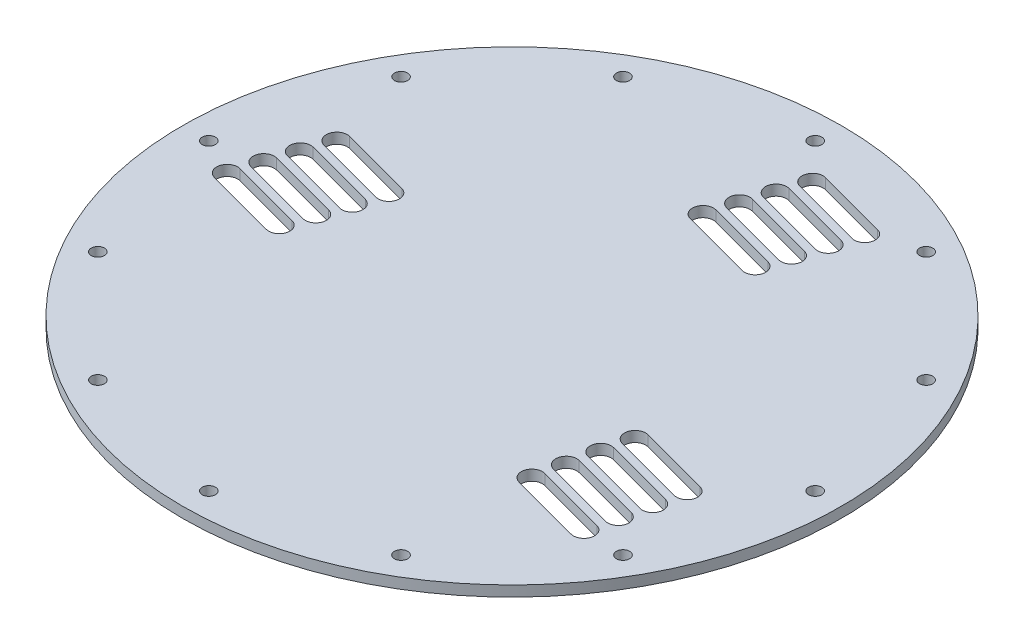
from build123d import *

# Parameters (mm, degrees)
SKETCH1_R           = 125
SKETCH1_R_2         = 2.5
BOSS_EXTRUDE1_DEPTH = 4


with BuildPart() as part:
    # Sketch1 → Boss-Extrude1 (new body)
    with BuildSketch(Plane(origin=(0, 0, 0), x_dir=(1, 0, 0), z_dir=(0, 1, 0))):
        Circle(SKETCH1_R)
        with Locations((-115, 0)):
            Circle(SKETCH1_R_2, mode=Mode.SUBTRACT)
        with Locations((-99.592921435, 57.5)):
            Circle(SKETCH1_R_2, mode=Mode.SUBTRACT)
        with Locations((-57.5, 99.592921435)):
            Circle(SKETCH1_R_2, mode=Mode.SUBTRACT)
        with Locations((0, 115)):
            Circle(SKETCH1_R_2, mode=Mode.SUBTRACT)
        with Locations((57.5, 99.592921435)):
            Circle(SKETCH1_R_2, mode=Mode.SUBTRACT)
        with Locations((99.592921435, 57.5)):
            Circle(SKETCH1_R_2, mode=Mode.SUBTRACT)
        with Locations((115, 0)):
            Circle(SKETCH1_R_2, mode=Mode.SUBTRACT)
        with Locations((99.592921435, -57.5)):
            Circle(SKETCH1_R_2, mode=Mode.SUBTRACT)
        with Locations((57.5, -99.592921435)):
            Circle(SKETCH1_R_2, mode=Mode.SUBTRACT)
        with Locations((0, -115)):
            Circle(SKETCH1_R_2, mode=Mode.SUBTRACT)
        with Locations((-57.5, -99.592921435)):
            Circle(SKETCH1_R_2, mode=Mode.SUBTRACT)
        with Locations((-99.592921435, -57.5)):
            Circle(SKETCH1_R_2, mode=Mode.SUBTRACT)
        with BuildLine():
            Line((-89.732773716, 28.184928973), (-62.744806129, 20.953524853))
            ThreePointArc((-62.744806129, 20.953524853), (-59.916379005, 16.054545368), (-64.81535849, 13.226118243))
            Line((-64.81535849, 13.226118243), (-91.803326077, 20.457522363))
            ThreePointArc((-91.803326077, 20.457522363), (-94.631753202, 25.356501849), (-89.732773716, 28.184928973))
        make_face(mode=Mode.SUBTRACT)
        with BuildLine():
            Line((-93.131960654, 17.723307294), (-66.143993068, 10.491903174))
            ThreePointArc((-66.143993068, 10.491903174), (-63.315565943, 5.592923688), (-68.214545428, 2.764496564))
            Line((-68.214545428, 2.764496564), (-95.202513015, 9.995900684))
            ThreePointArc((-95.202513015, 9.995900684), (-98.03094014, 14.894880169), (-93.131960654, 17.723307294))
        make_face(mode=Mode.SUBTRACT)
        with BuildLine():
            Line((-96.531147592, 7.261685615), (-69.543180006, 0.030281495))
            ThreePointArc((-69.543180006, 0.030281495), (-66.714752881, -4.868697991), (-71.613732367, -7.697125116))
            Line((-71.613732367, -7.697125116), (-98.601699953, -0.465720995))
            ThreePointArc((-98.601699953, -0.465720995), (-101.430127078, 4.43325849), (-96.531147592, 7.261685615))
        make_face(mode=Mode.SUBTRACT)
        with BuildLine():
            Line((-99.93033453, -3.199936064), (-72.942366944, -10.431340184))
            ThreePointArc((-72.942366944, -10.431340184), (-70.113939819, -15.33031967), (-75.012919305, -18.158746795))
            Line((-75.012919305, -18.158746795), (-102.000886891, -10.927342675))
            ThreePointArc((-102.000886891, -10.927342675), (-104.829314016, -6.028363189), (-99.93033453, -3.199936064))
        make_face(mode=Mode.SUBTRACT)
        with BuildLine():
            Line((91.803326077, -20.457522363), (64.81535849, -13.226118243))
            ThreePointArc((64.81535849, -13.226118243), (59.916379005, -16.054545368), (62.744806129, -20.953524853))
            Line((62.744806129, -20.953524853), (89.732773716, -28.184928973))
            ThreePointArc((89.732773716, -28.184928973), (94.631753202, -25.356501849), (91.803326077, -20.457522363))
        make_face(mode=Mode.SUBTRACT)
        with BuildLine():
            Line((89.516297478, -31.217145971), (62.528329891, -23.985741851))
            ThreePointArc((62.528329891, -23.985741851), (57.629350406, -26.814168976), (60.45777753, -31.713148461))
            Line((60.45777753, -31.713148461), (87.445745117, -38.944552582))
            ThreePointArc((87.445745117, -38.944552582), (92.344724603, -36.116125457), (89.516297478, -31.217145971))
        make_face(mode=Mode.SUBTRACT)
        with BuildLine():
            Line((87.229268879, -41.976769579), (60.241301292, -34.745365459))
            ThreePointArc((60.241301292, -34.745365459), (55.342321807, -37.573792584), (58.170748931, -42.472772069))
            Line((58.170748931, -42.472772069), (85.158716518, -49.70417619))
            ThreePointArc((85.158716518, -49.70417619), (90.057696004, -46.875749065), (87.229268879, -41.976769579))
        make_face(mode=Mode.SUBTRACT)
        with BuildLine():
            Line((84.94224028, -52.736393187), (57.954272693, -45.504989067))
            ThreePointArc((57.954272693, -45.504989067), (53.055293208, -48.333416192), (55.883720332, -53.232395677))
            Line((55.883720332, -53.232395677), (82.871687919, -60.463799798))
            ThreePointArc((82.871687919, -60.463799798), (87.770667405, -57.635372673), (84.94224028, -52.736393187))
        make_face(mode=Mode.SUBTRACT)
        with BuildLine():
            Line((14.021652384, 104.900536337), (41.00961997, 97.669132217))
            ThreePointArc((41.00961997, 97.669132217), (43.838047095, 92.770152731), (38.939067609, 89.941725607))
            Line((38.939067609, 89.941725607), (11.951100023, 97.173129727))
            ThreePointArc((11.951100023, 97.173129727), (9.122672898, 102.072109212), (14.021652384, 104.900536337))
        make_face(mode=Mode.SUBTRACT)
        with BuildLine():
            Line((10.622465446, 94.438914658), (37.610433032, 87.207510538))
            ThreePointArc((37.610433032, 87.207510538), (40.438860157, 82.308531052), (35.539880671, 79.480103927))
            Line((35.539880671, 79.480103927), (8.551913085, 86.711508048))
            ThreePointArc((8.551913085, 86.711508048), (5.72348596, 91.610487533), (10.622465446, 94.438914658))
        make_face(mode=Mode.SUBTRACT)
        with BuildLine():
            Line((7.223278507, 83.977292979), (34.211246094, 76.745888859))
            ThreePointArc((34.211246094, 76.745888859), (37.039673219, 71.846909373), (32.140693733, 69.018482248))
            Line((32.140693733, 69.018482248), (5.152726147, 76.249886368))
            ThreePointArc((5.152726147, 76.249886368), (2.324299022, 81.148865854), (7.223278507, 83.977292979))
        make_face(mode=Mode.SUBTRACT)
        with BuildLine():
            Line((3.824091569, 73.515671299), (30.812059156, 66.284267179))
            ThreePointArc((30.812059156, 66.284267179), (33.640486281, 61.385287694), (28.741506795, 58.556860569))
            Line((28.741506795, 58.556860569), (1.753539208, 65.788264689))
            ThreePointArc((1.753539208, 65.788264689), (-1.074887916, 70.687244175), (3.824091569, 73.515671299))
        make_face(mode=Mode.SUBTRACT)
    extrude(amount=BOSS_EXTRUDE1_DEPTH)


solid = part.part
